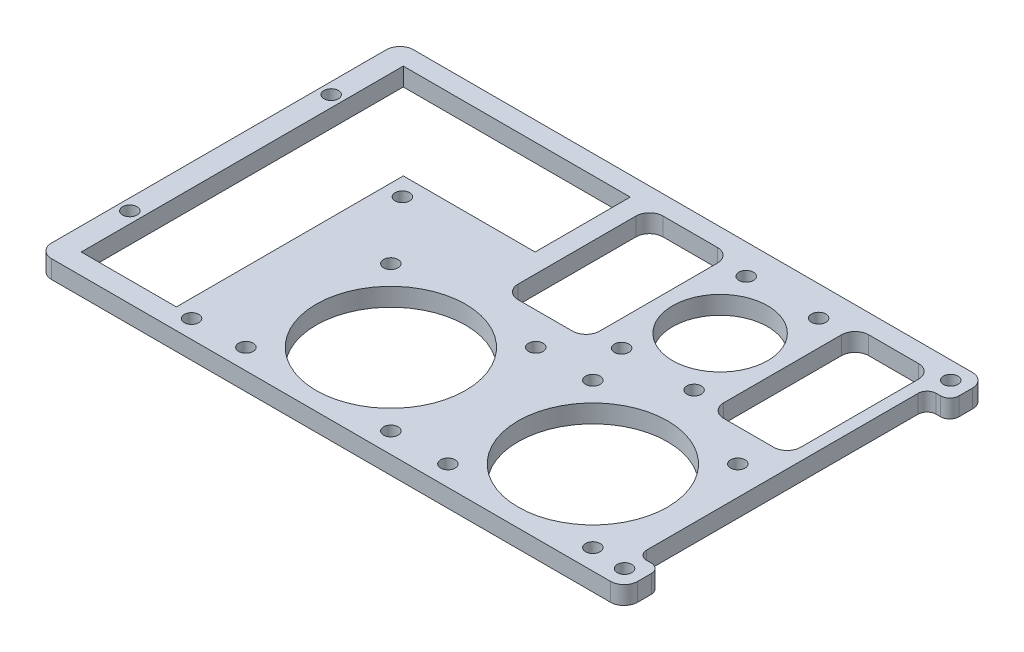
from build123d import *

# Parameters (mm, degrees)
SKETCH1_W           = 129.4
SKETCH1_H           = 79.9
BOSS_EXTRUDE1_DEPTH = 4
FILLET1_R           = 3
CUT_EXTRUDE1_DEPTH  = 10
SKETCH3_R           = 10.5
SKETCH3_R_2         = 1.6
SKETCH3_R_3         = 16.5
CUT_EXTRUDE2_DEPTH  = 10
SKETCH4_R           = 1.6
CUT_EXTRUDE3_DEPTH  = 10
SKETCH5_W           = 18
SKETCH5_H           = 32
SKETCH5_W_2         = 17
CUT_EXTRUDE4_DEPTH  = 10
SKETCH6_W           = 5
SKETCH6_H           = 63.9
CUT_EXTRUDE5_DEPTH  = 10
FILLET2_R           = 2
SKETCH7_R           = 1.6
CUT_EXTRUDE6_DEPTH  = 10
FILLET3_R           = 3


with BuildPart() as part:
    # Sketch1 → Boss-Extrude1 (new body)
    with BuildSketch(Plane(origin=(0, 0, 0), x_dir=(1, 0, 0), z_dir=(0, 1, 0))):
        with Locations((64.7, 39.95)):
            Rectangle(SKETCH1_W, SKETCH1_H)
    extrude(amount=BOSS_EXTRUDE1_DEPTH)

    # Fillet1
    fillet1_edges = [part.edges().sort_by_distance(p)[0] for p in [
        (0, 2, -79.9),
        (129.4, 2, -79.9),
        (129.4, 2, 0),
        (0, 2, 0),
    ]]
    fillet(fillet1_edges, radius=FILLET1_R)

    # Sketch2 → Cut-Extrude1 (cut)
    with BuildSketch(Plane(origin=(0, 4, 0), x_dir=(1, 0, 0), z_dir=(0, 1, 0))):
        Polygon((5, 4.55), (26, 4.55), (26, 54.65), (55.1, 54.65), (55.1, 75.65), (5, 75.65), (5, 40), align=None)
    extrude(amount=-CUT_EXTRUDE1_DEPTH, mode=Mode.SUBTRACT)

    # Sketch3 → Cut-Extrude2 (cut)
    with BuildSketch(Plane(origin=(0, 4, 0), x_dir=(1, 0, 0), z_dir=(0, 1, 0))):
        with Locations((91.05, 59.55)):
            Circle(SKETCH3_R)
        with Locations((83.05, 73.3)):
            Circle(SKETCH3_R_2)
        with Locations((99.05, 73.3)):
            Circle(SKETCH3_R_2)
        with Locations((99.05, 45.8)):
            Circle(SKETCH3_R_2)
        with Locations((83.05, 45.8)):
            Circle(SKETCH3_R_2)
        with Locations((41.4, 36.5)):
            Circle(SKETCH3_R_2)
        with Locations((73.4, 36.5)):
            Circle(SKETCH3_R_2)
        with Locations((86, 36.5)):
            Circle(SKETCH3_R_2)
        with Locations((118, 36.5)):
            Circle(SKETCH3_R_2)
        with Locations((102, 20.5)):
            Circle(SKETCH3_R_3)
        with Locations((57.4, 20.5)):
            Circle(SKETCH3_R_3)
        with Locations((41.4, 4.5)):
            Circle(SKETCH3_R_2)
        with Locations((73.4, 4.5)):
            Circle(SKETCH3_R_2)
        with Locations((86, 4.5)):
            Circle(SKETCH3_R_2)
        with Locations((118, 4.5)):
            Circle(SKETCH3_R_2)
    extrude(amount=-CUT_EXTRUDE2_DEPTH, mode=Mode.SUBTRACT)

    # Sketch4 → Cut-Extrude3 (cut)
    with BuildSketch(Plane(origin=(0, 4, 0), x_dir=(1, 0, 0), z_dir=(0, 1, 0))):
        with Locations((125.5, 4)):
            Circle(SKETCH4_R)
        with Locations((125.5, 76)):
            Circle(SKETCH4_R)
        with Locations((29.9, 50.55)):
            Circle(SKETCH4_R)
        with Locations((29.9, 4)):
            Circle(SKETCH4_R)
    extrude(amount=-CUT_EXTRUDE3_DEPTH, mode=Mode.SUBTRACT)

    # Sketch5 → Cut-Extrude4 (cut)
    with BuildSketch(Plane(origin=(0, 4, 0), x_dir=(1, 0, 0), z_dir=(0, 1, 0))):
        with Locations((68.35, 59.65)):
            Rectangle(SKETCH5_W, SKETCH5_H)
        with Locations((113.25, 59.65)):
            Rectangle(SKETCH5_W_2, SKETCH5_H)
    extrude(amount=-CUT_EXTRUDE4_DEPTH, mode=Mode.SUBTRACT)

    # Sketch6 → Cut-Extrude5 (cut)
    with BuildSketch(Plane(origin=(0, 4, 0), x_dir=(1, 0, 0), z_dir=(0, 1, 0))):
        with Locations((126.9, 39.95)):
            Rectangle(SKETCH6_W, SKETCH6_H)
    extrude(amount=-CUT_EXTRUDE5_DEPTH, mode=Mode.SUBTRACT)

    # Fillet2
    fillet2_edges = [part.edges().sort_by_distance(p)[0] for p in [
        (129.4, 2, -71.9),
        (129.4, 2, -8),
        (124.4, 2, -8),
        (124.4, 2, -71.9),
    ]]
    fillet(fillet2_edges, radius=FILLET2_R)

    # Sketch7 → Cut-Extrude6 (cut)
    with BuildSketch(Plane(origin=(0, 0, 0), x_dir=(-1, 0, 0), z_dir=(0, -1, 0))):
        with Locations((-2.5, 17.775)):
            Circle(SKETCH7_R)
        with Locations((-2.5, 62.225)):
            Circle(SKETCH7_R)
    extrude(amount=-CUT_EXTRUDE6_DEPTH, mode=Mode.SUBTRACT)

    # Fillet3
    fillet3_edges = [part.edges().sort_by_distance(p)[0] for p in [
        (77.35, 2, -43.65),
        (59.35, 2, -43.65),
        (59.35, 2, -75.65),
        (77.35, 2, -75.65),
        (121.75, 2, -75.65),
        (121.75, 2, -43.65),
        (104.75, 2, -43.65),
        (104.75, 2, -75.65),
    ]]
    fillet(fillet3_edges, radius=FILLET3_R)


solid = part.part
